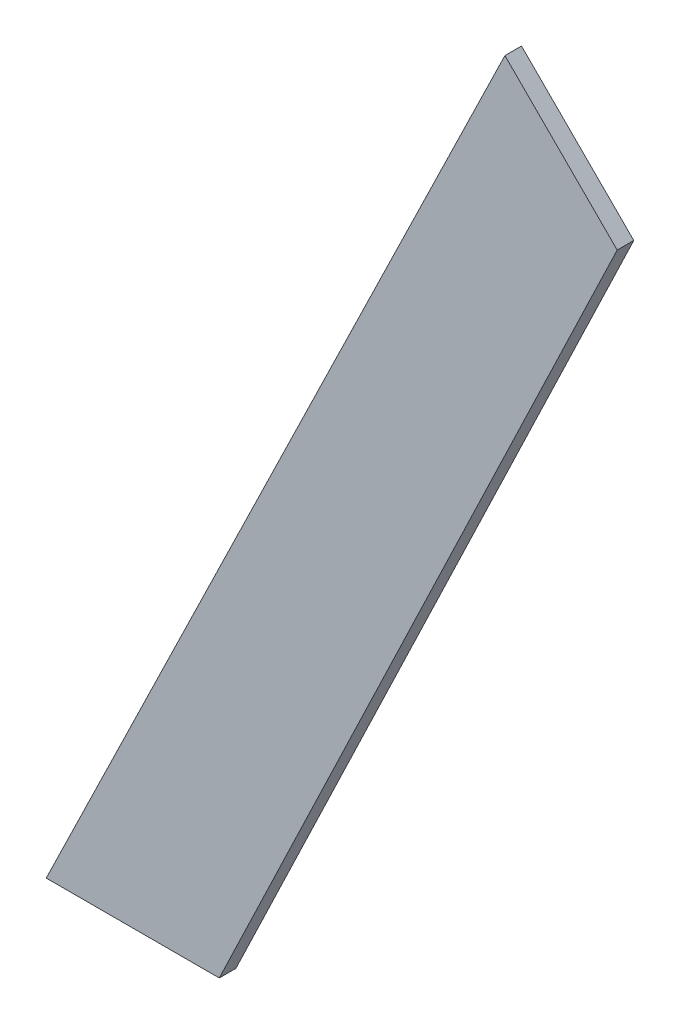
from build123d import *

# Parameters (mm, degrees)
BOSS_EXTRUDE1_DEPTH = 2


with BuildPart() as part:
    # Sketch1 → Boss-Extrude1 (new body)
    with BuildSketch(Plane.XY):
        Polygon((-158.472765207, 20.866209459), (-172.009805754, 34.403250006), (-227.315546686, -79.133790541), (-206.448951296, -79.133790541), align=None)
    extrude(amount=-BOSS_EXTRUDE1_DEPTH)


solid = part.part
